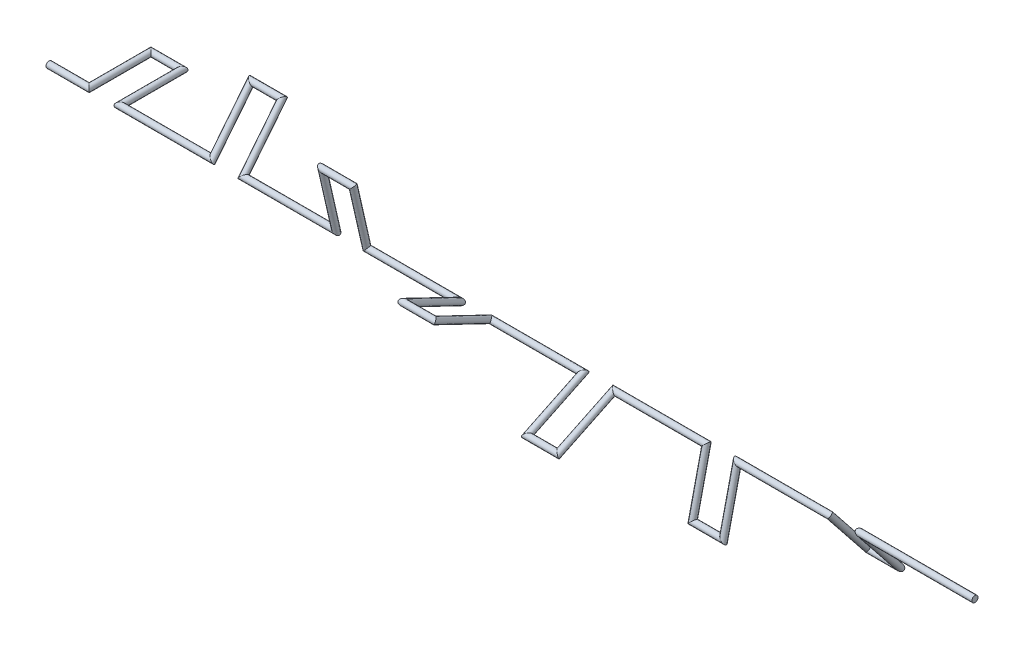
from build123d import *

# Parameters (mm, degrees)
SKETCH5_R = 1


with BuildPart() as part:
    # Sweep1: sweep along a curve in space
    with BuildLine() as sweep1_path:
        Line((13, 0, 0), (0, 0, 0))
        Line((13, 0, -20), (13, 0, 0))
        Line((23, 0, -20), (13, 0, -20))
        Line((23, 0, 0), (23, 0, -20))
        Line((53, 0, 0), (23, 0, 0))
        Line((53, 0, 0), (53, 15.636629649, -12.469796037))
        Line((53, 15.636629649, -12.469796037), (63, 15.636629649, -12.469796037))
        Line((63, 15.636629649, -12.469796037), (63, 0, 0))
        Line((63, 0, 0), (93, 0, 0))
        Line((93, 0, 0), (93, 19.498558244, 4.450418679))
        Line((93, 19.498558244, 4.450418679), (103, 19.498558244, 4.450418679))
        Line((103, 19.498558244, 4.450418679), (103, 0, 0))
        Line((103, 0, 0), (133, 0, 0))
        Line((133, 0, 0), (133, 8.677674782, 18.019377358))
        Line((133, 8.677674782, 18.019377358), (143, 8.677674782, 18.019377358))
        Line((143, 8.677674782, 18.019377358), (143, 0, 0))
        Line((143, 0, 0), (173, 0, 0))
        Line((173, 0, 0), (173, -8.677674782, 18.019377358))
        Line((173, -8.677674782, 18.019377358), (183, -8.677674782, 18.019377358))
        Line((183, -8.677674782, 18.019377358), (183, 0, 0))
        Line((183, 0, 0), (213, 0, 0))
        Line((213, 0, 0), (213, -19.498558244, 4.450418679))
        Line((213, -19.498558244, 4.450418679), (223, -19.498558244, 4.450418679))
        Line((223, -19.498558244, 4.450418679), (223, 0, 0))
        Line((223, 0, 0), (253, 0, 0))
        Line((253, 0, 0), (253, -15.636629649, -12.469796037))
        Line((253, -15.636629649, -12.469796037), (263, -15.636629649, -12.469796037))
        Line((263, -15.636629649, -12.469796037), (263, 0, 0))
        Line((263, 0, 0), (300, 0, 0))
    # Sketch5 → Sweep1 (sweep)
    with BuildSketch(Plane(origin=(0, 0, 0), x_dir=(0, 0, -1), z_dir=(1, 0, 0))):
        Circle(SKETCH5_R)
    sweep(path=sweep1_path.line, transition=Transition.RIGHT)


solid = part.part
